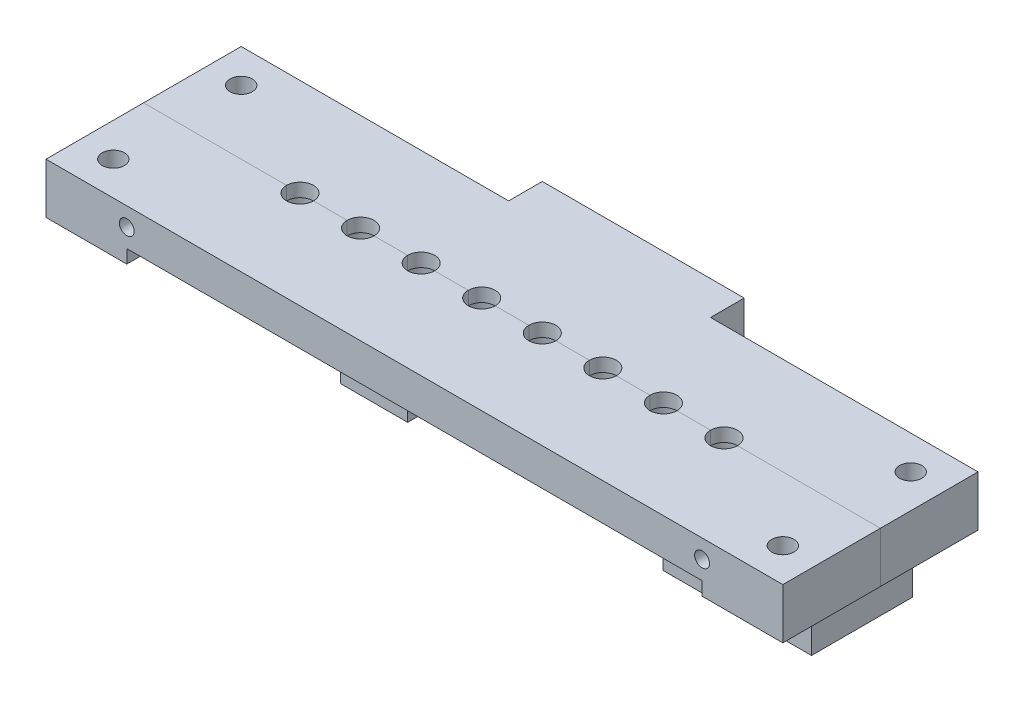
from build123d import *

# Parameters (mm, degrees)
BOSS_EXTRUDE1_DEPTH      = 14.5
LPATTERN1_COUNT          = 8
LPATTERN1_PITCH          = 9
SKETCH4_R                = 1.65
CUT_EXTRUDE1_DEPTH       = 7.5
SKETCH5_W                = 85.48
SKETCH5_H                = 5
CUT_EXTRUDE2_DEPTH       = 2
SKETCH16_R               = 1.1
CUT_EXTRUDE5_DEPTH       = 29
SKETCH8_W                = 30
SKETCH8_H                = 5.5
BOSS_EXTRUDE3_DEPTH      = 5
SKETCH9_W                = 30
SKETCH9_H                = 5
BOSS_EXTRUDE4_DEPTH      = 25.5
SKETCH10_W               = 5
SKETCH10_H               = 5
BOSS_EXTRUDE5_DEPTH      = 20
BOSS_EXTRUDE5_DEPTH_BACK = 50
SKETCH11_R               = 1.65
CUT_EXTRUDE3_DEPTH       = 5
SKETCH12_W               = 10
SKETCH12_H               = 5
BOSS_EXTRUDE6_DEPTH      = 5
SKETCH13_W               = 10
SKETCH13_H               = 5
BOSS_EXTRUDE7_DEPTH      = 5
CHAMFER2_SIZE            = 10
BOSS_EXTRUDE8_DEPTH      = 5
SKETCH15_R               = 1.65
CUT_EXTRUDE4_DEPTH       = 5


with BuildPart() as part:
    # Sketch1 → Boss-Extrude1 (new body, symmetric)
    with BuildSketch(Plane.XY):
        Polygon((-54.74, -3.75), (-35.4, -3.75), (-35.4, -2.25), (-33.5, -2.25), (-33.5, -1.25), (-34.25, -1.25), (-34.25, 1.75), (-33.5, 1.75), (-33.5, 3.75), (-54.74, 3.75), align=None)
        Polygon((-35.4, -3.75), (54.74, -3.75), (54.74, 3.75), (-33.5, 3.75), (-33.5, 1.75), (-34.25, 1.75), (-34.25, -1.25), (-33.5, -1.25), (-33.5, -2.25), (-35.4, -2.25), align=None)
    extrude(amount=BOSS_EXTRUDE1_DEPTH, both=True)

    # Sketch2 → Cut-Revolve2 (revolve, cut)
    with BuildSketch(Plane.XY):
        Polygon((-31.5, 3.75), (-31.5, -3.75), (-35.4, -3.75), (-35.4, -2.25), (-33.5, -2.25), (-33.5, -1.25), (-34.25, -1.25), (-34.25, 1.75), (-33.5, 1.75), (-33.5, 3.75), align=None)
    cut_revolve2 = revolve(axis=Axis((-31.5, 3.75, 0), (0, -1, 0)), mode=Mode.SUBTRACT)

    # LPattern1: Cut-Revolve2 ×8
    with Locations(*[(i * LPATTERN1_PITCH, 0, 0) for i in range(1, LPATTERN1_COUNT)]):
        add(cut_revolve2, mode=Mode.SUBTRACT)

    # Sketch4 → Cut-Extrude1 (cut)
    with BuildSketch(Plane(origin=(0, 3.75, 0), x_dir=(1, 0, 0), z_dir=(0, 1, 0))):
        with Locations((-49.74, 9.5)):
            Circle(SKETCH4_R)
        with Locations((49.74, 9.5)):
            Circle(SKETCH4_R)
        with Locations((49.74, -9.5)):
            Circle(SKETCH4_R)
        with Locations((-49.74, -9.5)):
            Circle(SKETCH4_R)
    extrude(amount=-CUT_EXTRUDE1_DEPTH, mode=Mode.SUBTRACT)

    # Sketch5 → Cut-Extrude2 (cut)
    with BuildSketch(Plane.XZ.offset(3.75)):
        with Locations((0, 12)):
            Rectangle(SKETCH5_W, SKETCH5_H)
        with Locations((0, -12)):
            Rectangle(SKETCH5_W, SKETCH5_H)
    extrude(amount=-CUT_EXTRUDE2_DEPTH, mode=Mode.SUBTRACT)

    # Sketch16 → Cut-Extrude5 (cut)
    with BuildSketch(Plane.XY.offset(14.5)):
        with Locations((-42.74, 1)):
            Circle(SKETCH16_R)
        with Locations((42.74, 1)):
            Circle(SKETCH16_R)
    extrude(amount=-CUT_EXTRUDE5_DEPTH, mode=Mode.SUBTRACT)

    # Sketch8 → Boss-Extrude3 (add)
    with BuildSketch(Plane(origin=(0, 0, -14.5), x_dir=(-1, 0, 0), z_dir=(0, 0, -1))):
        with Locations((0, 1)):
            Rectangle(SKETCH8_W, SKETCH8_H)
    extrude(amount=BOSS_EXTRUDE3_DEPTH)

    # Sketch9 → Boss-Extrude4 (add)
    with BuildSketch(Plane.XZ.offset(1.75)):
        with Locations((0, -17)):
            Rectangle(SKETCH9_W, SKETCH9_H)
    extrude(amount=BOSS_EXTRUDE4_DEPTH)

    # Sketch10 → Boss-Extrude5 (add, two sides)
    with BuildSketch(Plane(origin=(15, 0, 0), x_dir=(0, 0, -1), z_dir=(1, 0, 0))) as boss_extrude5_sk:
        with Locations((17, -24.75)):
            Rectangle(SKETCH10_W, SKETCH10_H)
    extrude(amount=BOSS_EXTRUDE5_DEPTH)
    extrude(boss_extrude5_sk.sketch, amount=-BOSS_EXTRUDE5_DEPTH_BACK)

    # Sketch11 → Cut-Extrude3 (cut)
    with BuildSketch(Plane(origin=(0, -22.25, 0), x_dir=(1, 0, 0), z_dir=(0, 1, 0))):
        with Locations((-30, 17)):
            Circle(SKETCH11_R)
        with Locations((30, 17)):
            Circle(SKETCH11_R)
    extrude(amount=-CUT_EXTRUDE3_DEPTH, mode=Mode.SUBTRACT)

    # Sketch12 → Boss-Extrude6 (add)
    with BuildSketch(Plane(origin=(0, 0, -19.5), x_dir=(-1, 0, 0), z_dir=(0, 0, -1))):
        with Locations((-30, -24.75)):
            Rectangle(SKETCH12_W, SKETCH12_H)
        with Locations((30, -24.75)):
            Rectangle(SKETCH12_W, SKETCH12_H)
    extrude(amount=BOSS_EXTRUDE6_DEPTH)

    # Sketch13 → Boss-Extrude7 (add)
    with BuildSketch(Plane.XY.offset(-14.5)):
        with Locations((-30, -24.75)):
            Rectangle(SKETCH13_W, SKETCH13_H)
        with Locations((30, -24.75)):
            Rectangle(SKETCH13_W, SKETCH13_H)
    extrude(amount=BOSS_EXTRUDE7_DEPTH)

    # Chamfer2
    chamfer2_edges = [part.edges().sort_by_distance(p)[0] for p in [
        (-15, -22.25, -17),
        (15, -22.25, -17),
    ]]
    chamfer(chamfer2_edges, length=CHAMFER2_SIZE)


with BuildPart() as body_2:
    # Split1: the piece on the far side of the plane
    add(part.part)
    split(bisect_by=Plane.XY, keep=Keep.BOTTOM)

    # Sketch14 → Boss-Extrude8 (add, symmetric)
    with BuildSketch(Plane.ZY):
        Polygon((-19.5, -12.25), (-27.419993495, -20.169993495), (-27.419993495, -45.25), (-32.419993495, -45.25), (-32.419993495, -18.098925683), (-19.5, -5.178932188), align=None)
    extrude(amount=BOSS_EXTRUDE8_DEPTH, both=True)

    # Sketch15 → Cut-Extrude4 (cut)
    with BuildSketch(Plane(origin=(0, 0, -32.419993495), x_dir=(-1, 0, 0), z_dir=(0, 0, -1))):
        with Locations((0, -37.25)):
            Circle(SKETCH15_R)
    extrude(amount=-CUT_EXTRUDE4_DEPTH, mode=Mode.SUBTRACT)


with BuildPart() as part_1:
    add(part.part)

    # Split1
    split(bisect_by=Plane.XY, keep=Keep.TOP)


solid = Compound([body_2.part, part_1.part])
